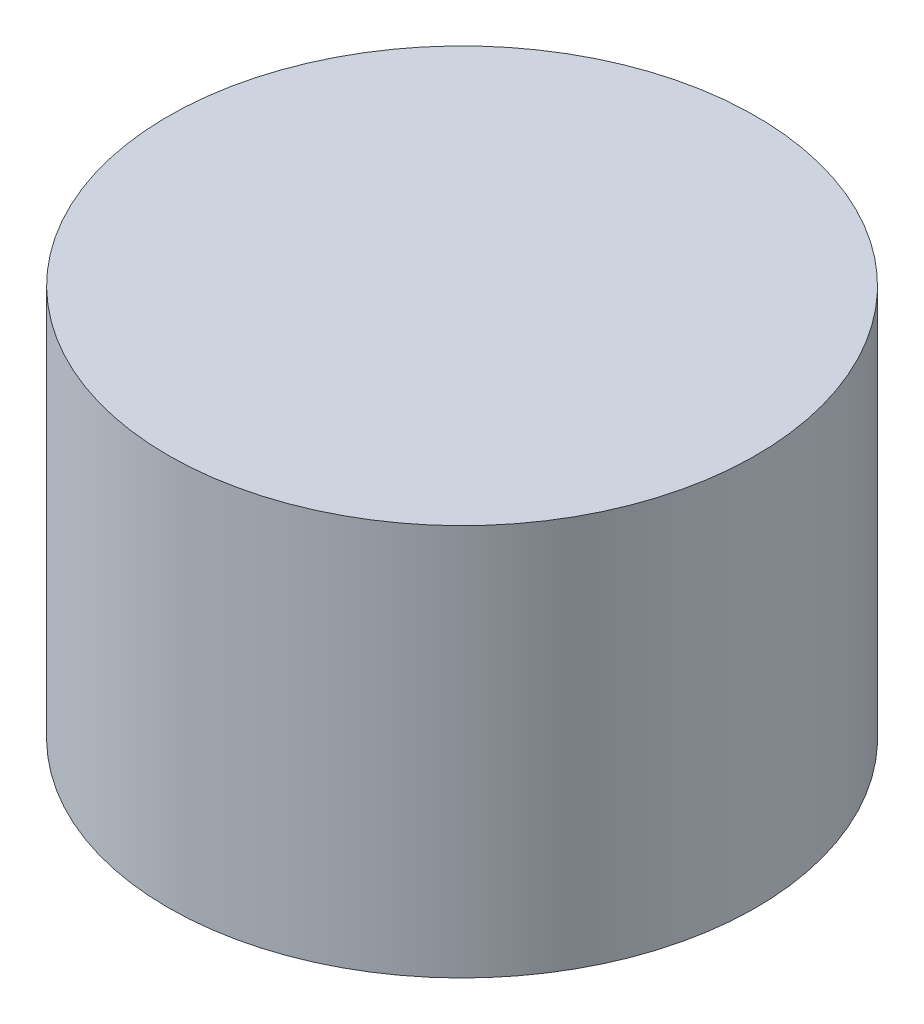
from build123d import *

# Parameters (mm, degrees)
SKETCH1_R           = 3
BOSS_EXTRUDE1_DEPTH = 4


with BuildPart() as part:
    # Sketch1 → Boss-Extrude1 (new body)
    with BuildSketch(Plane(origin=(0, 0, 0), x_dir=(1, 0, 0), z_dir=(0, 1, 0))):
        Circle(SKETCH1_R)
    extrude(amount=BOSS_EXTRUDE1_DEPTH)


solid = part.part
